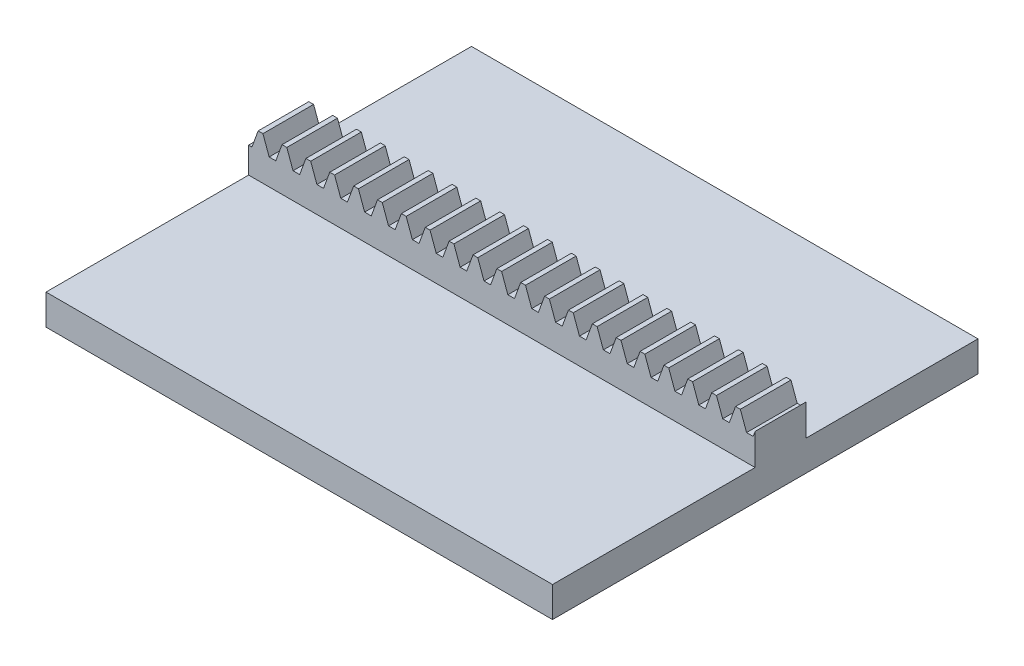
from build123d import *

# Parameters (mm, degrees)
BLANKSKE_W          = 100
BLANKSKE_H          = 11.5
BLANK_DEPTH         = 10
TOOTHCUTSIM_DEPTH   = 102.154584671
TEETHCUTS_COUNT     = 22
TEETHCUTS_PITCH     = 4.712388975
SKETCH2_W           = 40
SKETCH2_H           = 3
SKETCH2_W_2         = 34.0000508
BOSS_EXTRUDE1_DEPTH = 100


with BuildPart() as part:
    # BlankSke → Blank (new body)
    with BuildSketch(Plane.XY):
        with Locations((50, 5.75)):
            Rectangle(BLANKSKE_W, BLANKSKE_H)
    extrude(amount=-BLANK_DEPTH)

    # TooCutSkeSim → ToothCutSim (cut, through all)
    with BuildSketch(Plane.XY):
        Polygon((0.654653055, 8.125), (-0.654653055, 8.125), (-1.892297439, 11.5254), (1.892297439, 11.5254), align=None)
    toothcutsim = extrude(amount=-TOOTHCUTSIM_DEPTH, mode=Mode.SUBTRACT)

    # TeethCuts: ToothCutSim ×22
    with Locations(*[(i * TEETHCUTS_PITCH, 0, 0) for i in range(1, TEETHCUTS_COUNT)]):
        add(toothcutsim, mode=Mode.SUBTRACT)

    # Sketch2 → Boss-Extrude1 (add)
    with BuildSketch(Plane(origin=(100, 0, 0), x_dir=(0, 0, -1), z_dir=(1, 0, 0))):
        with Locations((-20, 1.5)):
            Rectangle(SKETCH2_W, SKETCH2_H)
        with Locations((27.0000254, 1.5)):
            Rectangle(SKETCH2_W_2, SKETCH2_H)
        Polygon((44.0000508, -3), (44.0000508, 0), (10, 0), (0, 0), (-40, 0), (-40, -3), align=None)
    extrude(amount=-BOSS_EXTRUDE1_DEPTH)


solid = part.part
